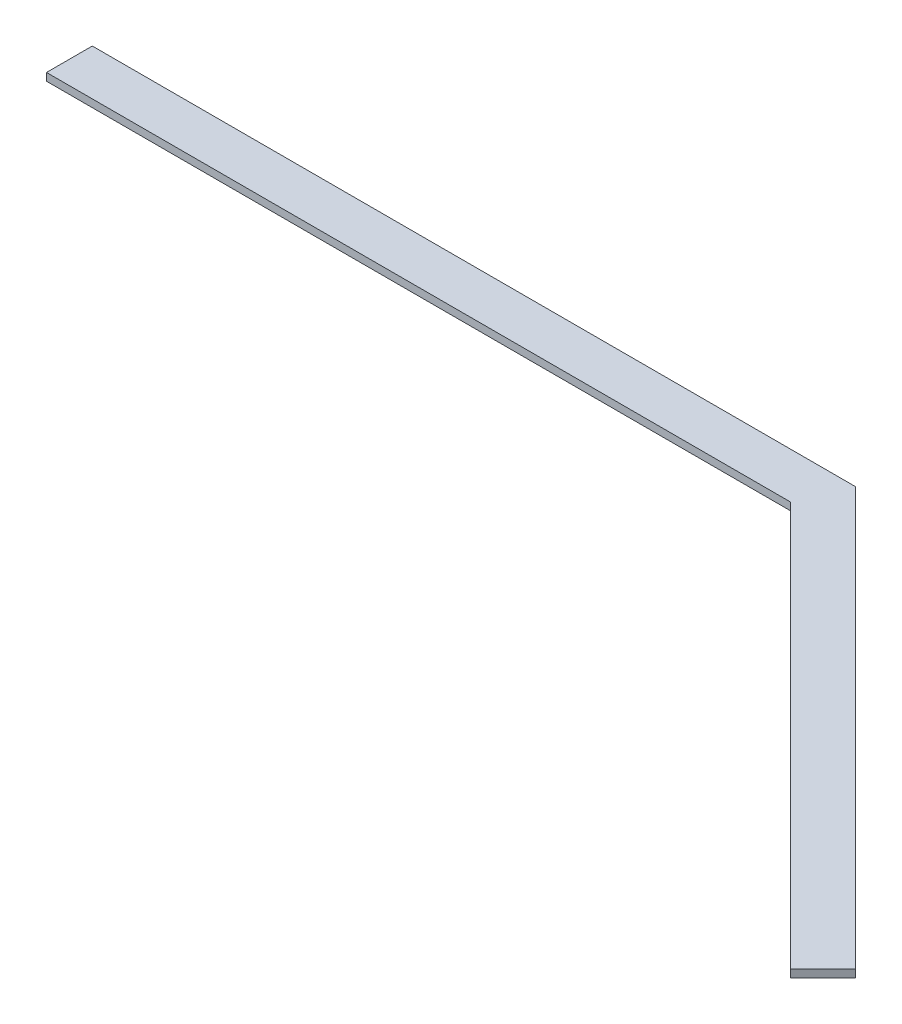
from build123d import *

# Parameters (mm, degrees)
BOSS_EXTRUDE1_DEPTH = 5


with BuildPart() as part:
    # Sketch1 → Boss-Extrude1 (new body)
    with BuildSketch(Plane(origin=(0, 0, 0), x_dir=(1, 0, 0), z_dir=(0, 1, 0))):
        Polygon((-273.786796564, 273.786796564), (-773.786796564, 273.786796564), (-773.786796564, 243.786796564), (-286.213203436, 243.786796564), (-21.213203436, -21.213203436), (0, 0), align=None)
    extrude(amount=BOSS_EXTRUDE1_DEPTH)


solid = part.part
